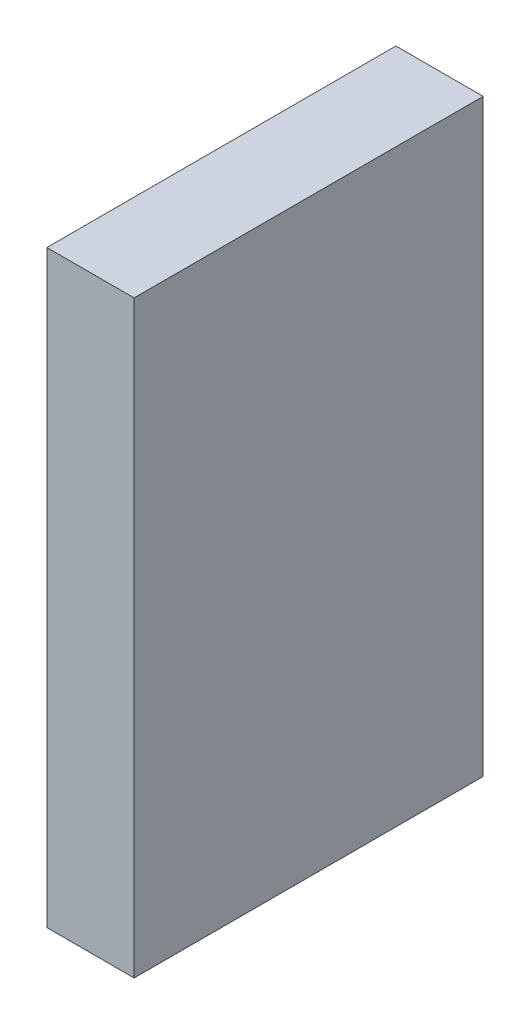
from build123d import *

# Parameters (mm, degrees)
SKETCH2_W           = 8
SKETCH2_H           = 13.5
BOSS_EXTRUDE1_DEPTH = 2


with BuildPart() as part:
    # Sketch2 → Boss-Extrude1 (new body)
    with BuildSketch(Plane(origin=(0, 0, 0), x_dir=(0, 0, -1), z_dir=(1, 0, 0))):
        Rectangle(SKETCH2_W, SKETCH2_H)
    extrude(amount=BOSS_EXTRUDE1_DEPTH)


solid = part.part
